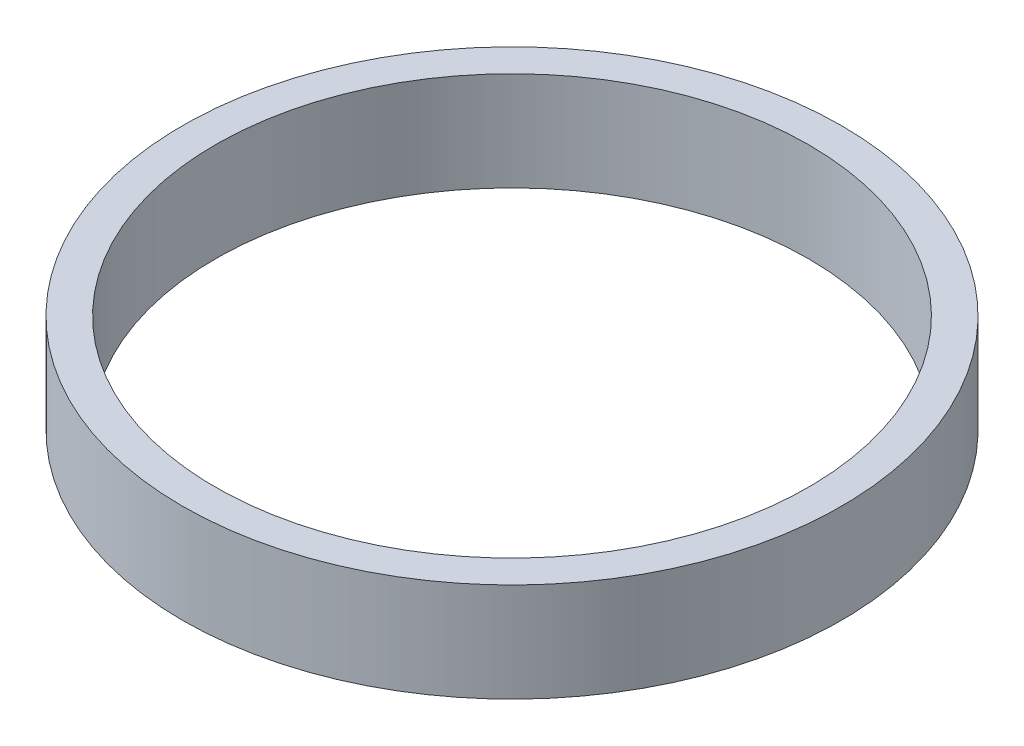
from build123d import *


with BuildPart() as part:
    # Sketch2 → Revolve1 (revolve)
    with BuildSketch(Plane.XY):
        Polygon((90, 0), (90, -15), (100, -15), (100, 15), (90, 15), align=None)
    revolve(axis=Axis((0, -45.654517339, 0), (0, 1, 0)))


solid = part.part
